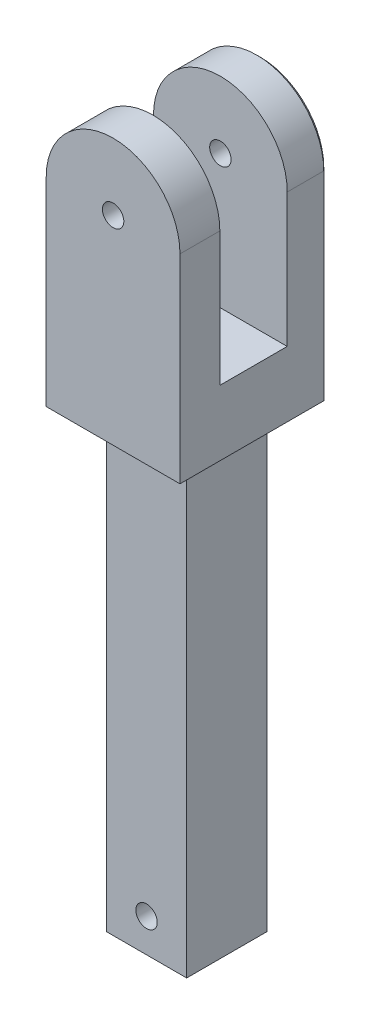
from build123d import *

# Parameters (mm, degrees)
SKETCH_1_R          = 1.6
EXTRUDE_1_DEPTH     = 12
CUT_EXTRUDE_1_DEPTH = 21
CUT_EXTRUDE_6_DEPTH = 21
SKETCH_12_R         = 1.6
EXTRUDE_11_DEPTH    = 5
SKETCH_13_R         = 1.6
EXTRUDE_12_DEPTH    = 5
SKETCH_14_W         = 2.04
SKETCH_14_H         = 20
CUT_EXTRUDE_7_DEPTH = 21
SKETCH_15_W         = 6
SKETCH_15_H         = 6
EXTRUDE_13_DEPTH    = 68
SKETCH_17_R         = 1.6
CUT_EXTRUDE_8_DEPTH = 18
CHAMFER_1_SIZE      = 0.5


with BuildPart() as part:
    # 草圖1 → 填料-伸長1 (new body)
    with BuildSketch(Plane.XY):
        with BuildLine():
            Line((-10, 0), (-10, -30.276417548))
            Line((-10, -30.276417548), (10, -30.276417548))
            Line((10, -30.276417548), (10, 0))
            ThreePointArc((10, 0), (0, 10), (-10, 0))
        make_face()
        Circle(SKETCH_1_R, mode=Mode.SUBTRACT)
    extrude(amount=EXTRUDE_1_DEPTH)

    # 草圖2 → 除料-伸長1 (cut, through all)
    with BuildSketch(Plane(origin=(10, 0, 0), x_dir=(0, 0, -1), z_dir=(1, 0, 0))):
        Polygon((-9, 0), (-6, 0), (-3, 0), (-3, 15.780779257), (-9, 15.780779257), align=None)
        Polygon((-3, 0), (-6, 0), (-9, 0), (-8.60053373, -20), (-3, -20), align=None)
    extrude(amount=-CUT_EXTRUDE_1_DEPTH, mode=Mode.SUBTRACT)

    # 草圖11 → 除料-伸長6 (cut, through all)
    with BuildSketch(Plane(origin=(10, 0, 0), x_dir=(0, 0, -1), z_dir=(1, 0, 0))):
        Polygon((-9, 0), (-9, -20), (-8.60053373, -20), align=None)
    extrude(amount=-CUT_EXTRUDE_6_DEPTH, mode=Mode.SUBTRACT)

    # 草圖12 → 填料-伸長11 (add)
    with BuildSketch(Plane.XY.offset(12)):
        with BuildLine():
            ThreePointArc((10, 0), (0, 10), (-10, 0))
            ThreePointArc((-10, 0), (0, -10), (10, 0))
        make_face()
        Circle(SKETCH_12_R, mode=Mode.SUBTRACT)
        with BuildLine():
            ThreePointArc((10, 0), (0, -10), (-10, 0))
            Line((-10, 0), (-10, -30.276417548))
            Line((-10, -30.276417548), (10, -30.276417548))
            Line((10, -30.276417548), (10, 0))
        make_face()
    extrude(amount=EXTRUDE_11_DEPTH)

    # 草圖13 → 填料-伸長12 (add)
    with BuildSketch(Plane(origin=(0, 0, 0), x_dir=(-1, 0, 0), z_dir=(0, 0, -1))):
        with BuildLine():
            ThreePointArc((10, 0), (0, 10), (-10, 0))
            ThreePointArc((-10, 0), (0, -10), (10, 0))
        make_face()
        Circle(SKETCH_13_R, mode=Mode.SUBTRACT)
        with BuildLine():
            ThreePointArc((10, 0), (0, -10), (-10, 0))
            Line((-10, 0), (-10, -30.276417548))
            Line((-10, -30.276417548), (10, -30.276417548))
            Line((10, -30.276417548), (10, 0))
        make_face()
    extrude(amount=EXTRUDE_12_DEPTH)

    # 草圖14 → 除料-伸長7 (cut, through all)
    with BuildSketch(Plane.ZY.offset(10)):
        Polygon((3, 0), (3, -20), (9, -20), (9, 0), (11.04, 0), (11.04, 10), (3, 10), (0.96, 10), (0.96, 0), align=None)
        with Locations((1.98, -10)):
            Rectangle(SKETCH_14_W, SKETCH_14_H)
        with Locations((10.02, -10)):
            Rectangle(SKETCH_14_W, SKETCH_14_H)
    extrude(amount=-CUT_EXTRUDE_7_DEPTH, mode=Mode.SUBTRACT)

    # 草圖15 → 填料-伸長13 (add)
    with BuildSketch(Plane.XZ.offset(30.276417548)):
        with Locations((3, 9)):
            Rectangle(SKETCH_15_W, SKETCH_15_H)
        with Locations((-3, 9)):
            Rectangle(SKETCH_15_W, SKETCH_15_H)
        with Locations((3, 3)):
            Rectangle(SKETCH_15_W, SKETCH_15_H)
        with Locations((-3, 3)):
            Rectangle(SKETCH_15_W, SKETCH_15_H)
    extrude(amount=EXTRUDE_13_DEPTH)

    # 草圖17 → 除料-伸長8 (cut, through all)
    with BuildSketch(Plane(origin=(0, 0, 0), x_dir=(-1, 0, 0), z_dir=(0, 0, -1))):
        with Locations((0, -93.276417548)):
            Circle(SKETCH_17_R)
    extrude(amount=-CUT_EXTRUDE_8_DEPTH, mode=Mode.SUBTRACT)

    # 導角1
    chamfer_1_edges = [part.edges().sort_by_distance(p)[0] for p in [
        (10, -30.276417548, 6),
        (-10, -30.276417548, 6),
        (0, -30.276417548, 17),
        (0, 10, -5),
        (10, -15.138208774, -5),
        (0, -30.276417548, -5),
        (-10, -15.138208774, -5),
    ]]
    chamfer(chamfer_1_edges, length=CHAMFER_1_SIZE)


solid = part.part
